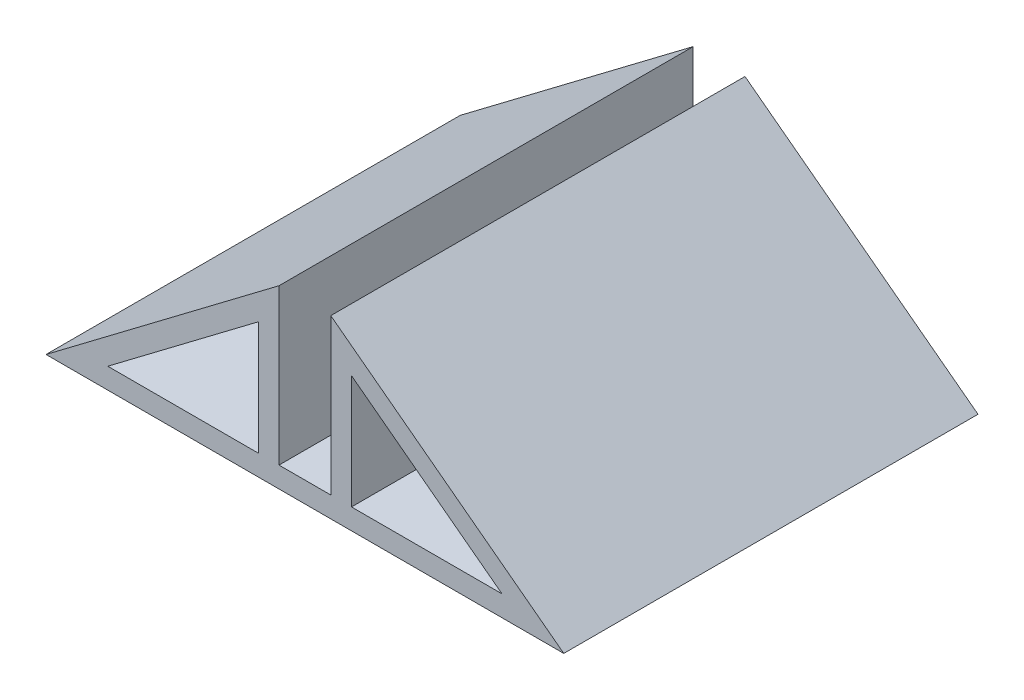
from build123d import *

# Parameters (mm, degrees)
BOSS_EXTRU_2_DEPTH = 40


with BuildPart() as part:
    # Esquisse1 → Boss.-Extru.2 (new body)
    with BuildSketch(Plane.XY):
        Polygon((-132.286889429, -48.932516673), (-154.786889429, -31.932516673), (-154.786889429, -46.932516673), (-159.786889429, -46.932516673), (-159.786889429, -31.932516673), (-182.286889429, -48.932516673), align=None)
        Polygon((-138.251616171, -46.932516673), (-152.786889429, -35.950310211), (-152.786889429, -46.932516673), align=None, mode=Mode.SUBTRACT)
        Polygon((-176.322162687, -46.932516673), (-161.786889429, -35.950310211), (-161.786889429, -46.932516673), align=None, mode=Mode.SUBTRACT)
    extrude(amount=BOSS_EXTRU_2_DEPTH)


solid = part.part
